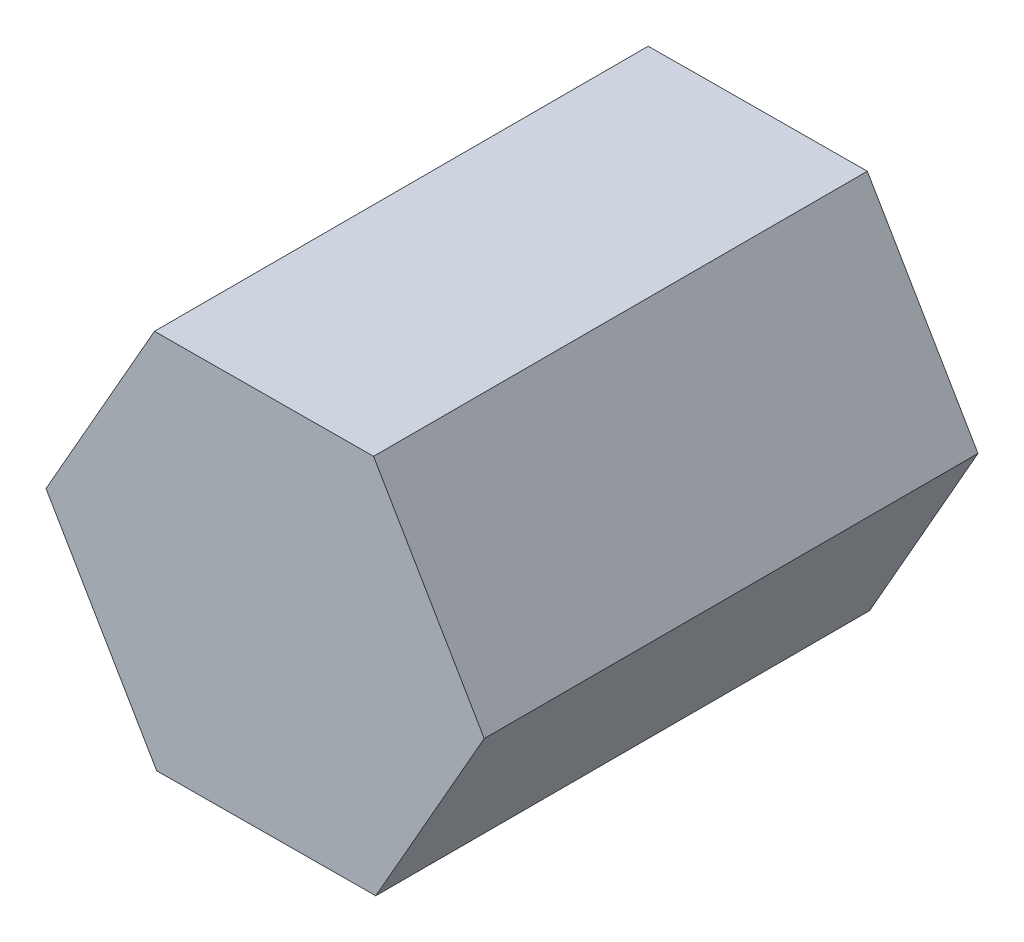
from build123d import *

# Parameters (mm, degrees)
ESTRUSIONE_ESTRUSIONE1_DEPTH = 160


with BuildPart() as part:
    # Schizzo1 → Estrusione-Estrusione1 (new body)
    with BuildSketch(Plane.XY):
        Polygon((-35.859477256, 61.278853538), (-70.998782507, -0.415791501), (-35.139305251, -61.694645039), (35.859477256, -61.278853538), (70.998782507, 0.415791501), (35.139305251, 61.694645039), align=None)
    extrude(amount=ESTRUSIONE_ESTRUSIONE1_DEPTH)


solid = part.part
